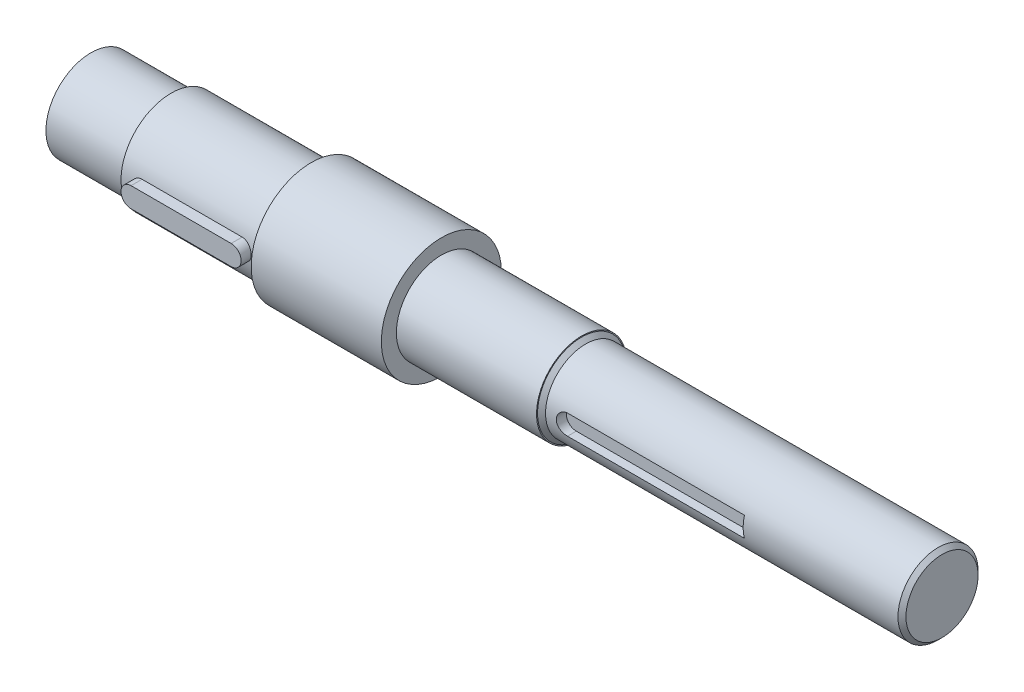
from build123d import *

# Parameters (mm, degrees)
CHAMFER1_SIZE       = 2
CUT_EXTRUDE2_DEPTH  = 5
CUT_EXTRUDE3_DEPTH  = 5
BOSS_EXTRUDE1_DEPTH = 10


with BuildPart() as part:
    # Sketch2 → Revolve1 (revolve)
    with BuildSketch(Plane(origin=(0, 0, 0), x_dir=(1, 0, 0), z_dir=(0, 1, 0))):
        Polygon((303.786030517, 20), (303.786030517, 0), (325, 0), (425, 0), (425, 20), (325, 20), align=None)
        Polygon((0, 22.5), (0, 0), (303.786030517, 0), (303.786030517, 20), (245, 20), (245, 22.5), (175, 22.5), (175, 30), (110, 30), (110, 25), (40, 25), (40, 22.5), align=None)
    revolve(axis=Axis((325, 0, 0), (-1, 0, 0)))

    # Chamfer1
    chamfer1_edges = [part.edges().sort_by_distance(p)[0] for p in [
        (425, 0, 20),
        (245, 0, 20),
    ]]
    chamfer(chamfer1_edges, length=CHAMFER1_SIZE)

    # Sketch4 → Cut-Extrude2 (cut)
    with BuildSketch(Plane.XY.offset(20)):
        with BuildLine():
            Line((257.357014361, -5), (345.693163579, -5))
            Line((345.693163579, -5), (345.693163579, 5))
            Line((345.693163579, 5), (257.357014361, 5))
            ThreePointArc((257.357014361, 5), (252.357014361, 0), (257.357014361, -5))
        make_face()
    extrude(amount=-CUT_EXTRUDE2_DEPTH, mode=Mode.SUBTRACT)

    # Sketch5 → Cut-Extrude3 (cut)
    with BuildSketch(Plane.XY.offset(25)):
        with BuildLine():
            Line((50, 5), (100, 5))
            ThreePointArc((100, 5), (105, 0), (100, -5))
            Line((100, -5), (50, -5))
            ThreePointArc((50, -5), (45, 0), (50, 5))
        make_face()
    extrude(amount=-CUT_EXTRUDE3_DEPTH, mode=Mode.SUBTRACT)

    # Sketch8 → Boss-Extrude1 (add)
    with BuildSketch(Plane.XY.offset(20)):
        with BuildLine():
            Line((100, 5), (50, 5))
            ThreePointArc((50, 5), (45, 0), (50, -5))
            Line((50, -5), (100, -5))
            ThreePointArc((100, -5), (105, 0), (100, 5))
        make_face()
    extrude(amount=BOSS_EXTRUDE1_DEPTH)


solid = part.part
